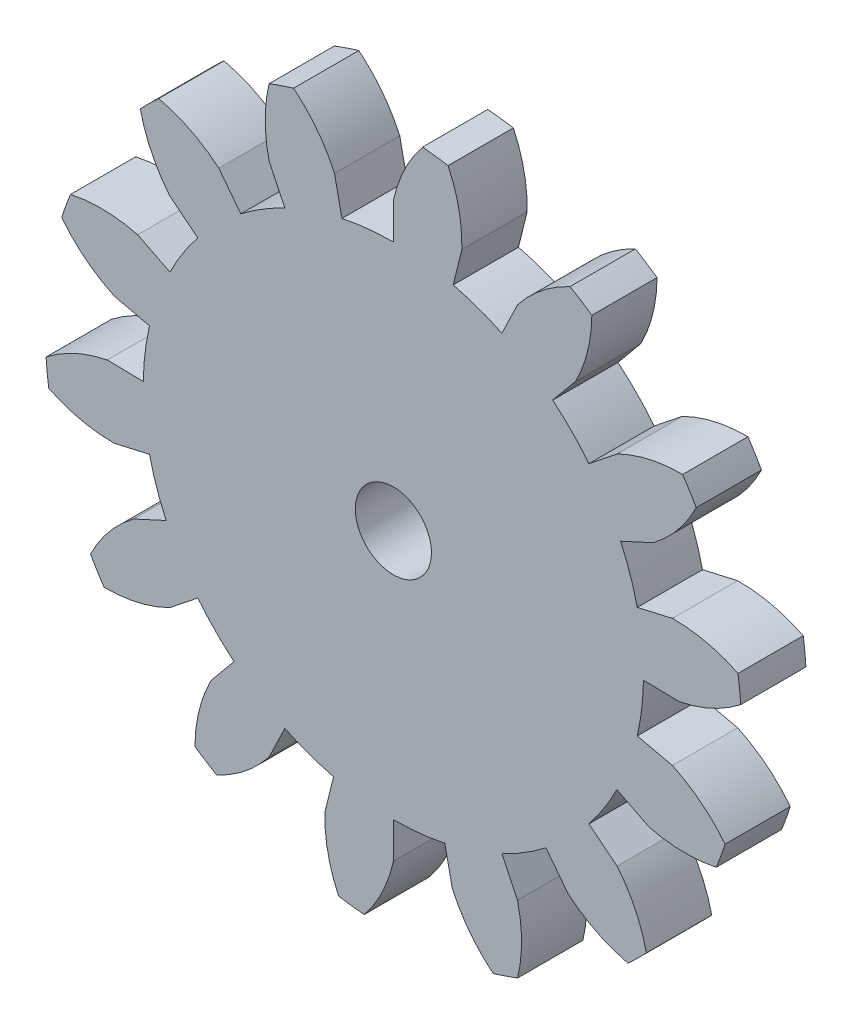
from build123d import *

# Parameters (mm, degrees)
BOSS_EXTRU_1_DEPTH           = 3
R_P_TITION_CIRCULAIRE2_COUNT = 14
ESQUISSE5_R                  = 11.5
BOSS_EXTRU_2_DEPTH           = 3
ESQUISSE6_R                  = 1.75
ENL_V_MAT_EXTRU_1_DEPTH      = 4


with BuildPart() as part:
    # Esquisse4 → Boss.-Extru.1 (new body)
    with BuildSketch(Plane.XY):
        with BuildLine():
            Line((0, 13.155696691), (0, 11.5))
            ThreePointArc((0, 11.5), (1.385979557, 11.416175396), (2.751754038, 11.165923594))
            Line((2.751754038, 11.165923594), (3.147934042, 12.773522094))
            ThreePointArc((3.147934042, 12.773522094), (3.010357566, 14.324173734), (2.517223611, 15.800746352))
            ThreePointArc((2.517223611, 15.800746352), (1.928319383, 15.883374464), (1.336751397, 15.944061456))
            ThreePointArc((1.336751397, 15.944061456), (0.504624377, 14.628382005), (0, 13.155696691))
        make_face()
    extrude(amount=BOSS_EXTRU_1_DEPTH)


with BuildPart() as r_p_tition_circulaire2_1:
    # Répétition circulaire2: pattern copy
    add(part.part.rotate(Axis((0, 0, 0), (0, 0, 1)), 1 * 360 / R_P_TITION_CIRCULAIRE2_COUNT))


with BuildPart() as r_p_tition_circulaire2_2:
    # Répétition circulaire2: pattern copy
    add(part.part.rotate(Axis((0, 0, 0), (0, 0, 1)), 2 * 360 / R_P_TITION_CIRCULAIRE2_COUNT))


with BuildPart() as r_p_tition_circulaire2_3:
    # Répétition circulaire2: pattern copy
    add(part.part.rotate(Axis((0, 0, 0), (0, 0, 1)), 3 * 360 / R_P_TITION_CIRCULAIRE2_COUNT))


with BuildPart() as r_p_tition_circulaire2_4:
    # Répétition circulaire2: pattern copy
    add(part.part.rotate(Axis((0, 0, 0), (0, 0, 1)), 4 * 360 / R_P_TITION_CIRCULAIRE2_COUNT))


with BuildPart() as r_p_tition_circulaire2_5:
    # Répétition circulaire2: pattern copy
    add(part.part.rotate(Axis((0, 0, 0), (0, 0, 1)), 5 * 360 / R_P_TITION_CIRCULAIRE2_COUNT))


with BuildPart() as r_p_tition_circulaire2_6:
    # Répétition circulaire2: pattern copy
    add(part.part.rotate(Axis((0, 0, 0), (0, 0, 1)), 6 * 360 / R_P_TITION_CIRCULAIRE2_COUNT))


with BuildPart() as r_p_tition_circulaire2_7:
    # Répétition circulaire2: pattern copy
    add(part.part.rotate(Axis((0, 0, 0), (0, 0, 1)), 7 * 360 / R_P_TITION_CIRCULAIRE2_COUNT))


with BuildPart() as r_p_tition_circulaire2_8:
    # Répétition circulaire2: pattern copy
    add(part.part.rotate(Axis((0, 0, 0), (0, 0, 1)), 8 * 360 / R_P_TITION_CIRCULAIRE2_COUNT))


with BuildPart() as r_p_tition_circulaire2_9:
    # Répétition circulaire2: pattern copy
    add(part.part.rotate(Axis((0, 0, 0), (0, 0, 1)), 9 * 360 / R_P_TITION_CIRCULAIRE2_COUNT))


with BuildPart() as r_p_tition_circulaire2_10:
    # Répétition circulaire2: pattern copy
    add(part.part.rotate(Axis((0, 0, 0), (0, 0, 1)), 10 * 360 / R_P_TITION_CIRCULAIRE2_COUNT))


with BuildPart() as r_p_tition_circulaire2_11:
    # Répétition circulaire2: pattern copy
    add(part.part.rotate(Axis((0, 0, 0), (0, 0, 1)), 11 * 360 / R_P_TITION_CIRCULAIRE2_COUNT))


with BuildPart() as r_p_tition_circulaire2_12:
    # Répétition circulaire2: pattern copy
    add(part.part.rotate(Axis((0, 0, 0), (0, 0, 1)), 12 * 360 / R_P_TITION_CIRCULAIRE2_COUNT))


with BuildPart() as r_p_tition_circulaire2_13:
    # Répétition circulaire2: pattern copy
    add(part.part.rotate(Axis((0, 0, 0), (0, 0, 1)), 13 * 360 / R_P_TITION_CIRCULAIRE2_COUNT))


with BuildPart() as part_1:
    add(part.part)

    add(r_p_tition_circulaire2_1.part)  # Boss.-Extru.2 merges Répétition circulaire2_1

    add(r_p_tition_circulaire2_2.part)  # Boss.-Extru.2 merges Répétition circulaire2_2

    add(r_p_tition_circulaire2_3.part)  # Boss.-Extru.2 merges Répétition circulaire2_3

    add(r_p_tition_circulaire2_4.part)  # Boss.-Extru.2 merges Répétition circulaire2_4

    add(r_p_tition_circulaire2_5.part)  # Boss.-Extru.2 merges Répétition circulaire2_5

    add(r_p_tition_circulaire2_6.part)  # Boss.-Extru.2 merges Répétition circulaire2_6

    add(r_p_tition_circulaire2_7.part)  # Boss.-Extru.2 merges Répétition circulaire2_7

    add(r_p_tition_circulaire2_8.part)  # Boss.-Extru.2 merges Répétition circulaire2_8

    add(r_p_tition_circulaire2_9.part)  # Boss.-Extru.2 merges Répétition circulaire2_9

    add(r_p_tition_circulaire2_10.part)  # Boss.-Extru.2 merges Répétition circulaire2_10

    add(r_p_tition_circulaire2_11.part)  # Boss.-Extru.2 merges Répétition circulaire2_11

    add(r_p_tition_circulaire2_12.part)  # Boss.-Extru.2 merges Répétition circulaire2_12

    add(r_p_tition_circulaire2_13.part)  # Boss.-Extru.2 merges Répétition circulaire2_13
    # Esquisse5 → Boss.-Extru.2 (add)
    with BuildSketch(Plane.XY):
        Circle(ESQUISSE5_R)
    extrude(amount=BOSS_EXTRU_2_DEPTH)

    # Esquisse6 → Enlèv. mat.-Extru.1 (cut, through all)
    with BuildSketch(Plane(origin=(0, 0, 0), x_dir=(-1, 0, 0), z_dir=(0, 0, -1))):
        Circle(ESQUISSE6_R)
    extrude(amount=-ENL_V_MAT_EXTRU_1_DEPTH, mode=Mode.SUBTRACT)


solid = part_1.part
